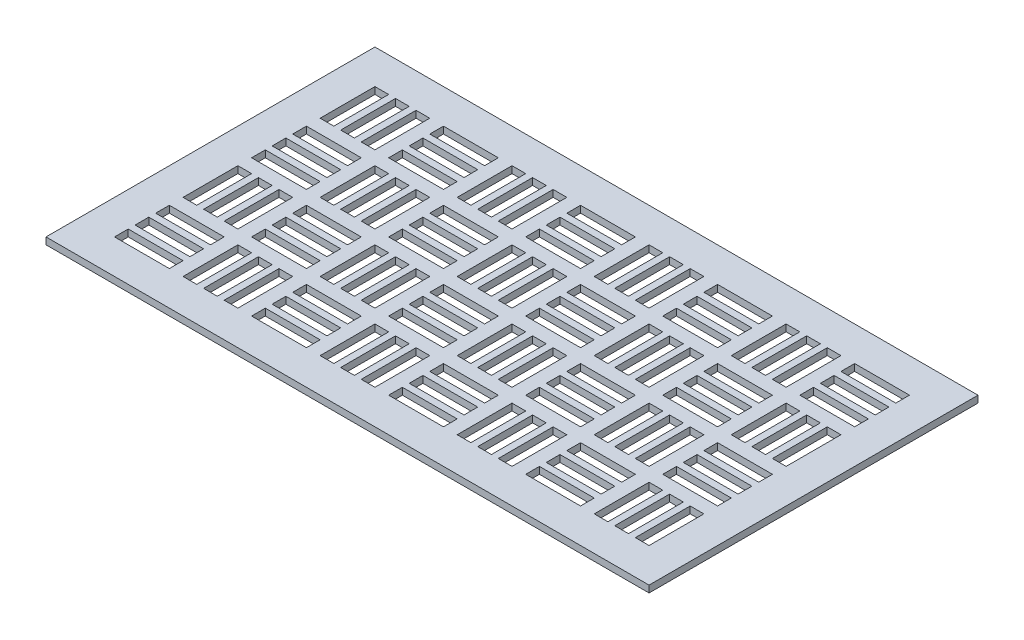
from build123d import *

# Parameters (mm, degrees)
SKETCH2_W           = 558.8
SKETCH2_H           = 304.8
SKETCH2_W_2         = 12.7
SKETCH2_H_2         = 50.8
SKETCH2_W_3         = 50.8
SKETCH2_H_3         = 12.7
BOSS_EXTRUDE1_DEPTH = 6.35


with BuildPart() as part:
    # Sketch2 → Boss-Extrude1 (new body)
    with BuildSketch(Plane(origin=(0, 0, 0), x_dir=(1, 0, 0), z_dir=(0, 1, 0))):
        with Locations((-49.563082079, -65.087132605)):
            Rectangle(SKETCH2_W, SKETCH2_H)
        with Locations((-290.863082079, 30.162867395)):
            Rectangle(SKETCH2_W_2, SKETCH2_H_2, mode=Mode.SUBTRACT)
        with Locations((-252.763082079, 30.162867395)):
            Rectangle(SKETCH2_W_2, SKETCH2_H_2, mode=Mode.SUBTRACT)
        with Locations((-208.313082079, 49.212867395)):
            Rectangle(SKETCH2_W_3, SKETCH2_H_3, mode=Mode.SUBTRACT)
        with Locations((-208.313082079, 11.112867395)):
            Rectangle(SKETCH2_W_3, SKETCH2_H_3, mode=Mode.SUBTRACT)
        with Locations((-227.363082079, -33.337132605)):
            Rectangle(SKETCH2_W_2, SKETCH2_H_2, mode=Mode.SUBTRACT)
        with Locations((-189.263082079, -33.337132605)):
            Rectangle(SKETCH2_W_2, SKETCH2_H_2, mode=Mode.SUBTRACT)
        with Locations((-271.813082079, -14.287132605)):
            Rectangle(SKETCH2_W_3, SKETCH2_H_3, mode=Mode.SUBTRACT)
        with Locations((-271.813082079, -52.387132605)):
            Rectangle(SKETCH2_W_3, SKETCH2_H_3, mode=Mode.SUBTRACT)
        with Locations((-271.813082079, 30.162867395)):
            Rectangle(SKETCH2_W_2, SKETCH2_H_2, mode=Mode.SUBTRACT)
        with Locations((-208.313082079, -33.337132605)):
            Rectangle(SKETCH2_W_2, SKETCH2_H_2, mode=Mode.SUBTRACT)
        with Locations((-208.313082079, 30.162867395)):
            Rectangle(SKETCH2_W_3, SKETCH2_H_3, mode=Mode.SUBTRACT)
        with Locations((-271.813082079, -33.337132605)):
            Rectangle(SKETCH2_W_3, SKETCH2_H_3, mode=Mode.SUBTRACT)
        with Locations((-163.863082079, 30.162867395)):
            Rectangle(SKETCH2_W_2, SKETCH2_H_2, mode=Mode.SUBTRACT)
        with Locations((-144.813082079, 30.162867395)):
            Rectangle(SKETCH2_W_2, SKETCH2_H_2, mode=Mode.SUBTRACT)
        with Locations((-125.763082079, 30.162867395)):
            Rectangle(SKETCH2_W_2, SKETCH2_H_2, mode=Mode.SUBTRACT)
        with Locations((-81.313082079, 11.112867395)):
            Rectangle(SKETCH2_W_3, SKETCH2_H_3, mode=Mode.SUBTRACT)
        with Locations((-81.313082079, 30.162867395)):
            Rectangle(SKETCH2_W_3, SKETCH2_H_3, mode=Mode.SUBTRACT)
        with Locations((-81.313082079, 49.212867395)):
            Rectangle(SKETCH2_W_3, SKETCH2_H_3, mode=Mode.SUBTRACT)
        with Locations((-62.263082079, -33.337132605)):
            Rectangle(SKETCH2_W_2, SKETCH2_H_2, mode=Mode.SUBTRACT)
        with Locations((-81.313082079, -33.337132605)):
            Rectangle(SKETCH2_W_2, SKETCH2_H_2, mode=Mode.SUBTRACT)
        with Locations((-100.363082079, -33.337132605)):
            Rectangle(SKETCH2_W_2, SKETCH2_H_2, mode=Mode.SUBTRACT)
        with Locations((-144.813082079, -52.387132605)):
            Rectangle(SKETCH2_W_3, SKETCH2_H_3, mode=Mode.SUBTRACT)
        with Locations((-144.813082079, -33.337132605)):
            Rectangle(SKETCH2_W_3, SKETCH2_H_3, mode=Mode.SUBTRACT)
        with Locations((-144.813082079, -14.287132605)):
            Rectangle(SKETCH2_W_3, SKETCH2_H_3, mode=Mode.SUBTRACT)
        with Locations((-36.863082079, 30.162867395)):
            Rectangle(SKETCH2_W_2, SKETCH2_H_2, mode=Mode.SUBTRACT)
        with Locations((-17.813082079, 30.162867395)):
            Rectangle(SKETCH2_W_2, SKETCH2_H_2, mode=Mode.SUBTRACT)
        with Locations((1.236917921, 30.162867395)):
            Rectangle(SKETCH2_W_2, SKETCH2_H_2, mode=Mode.SUBTRACT)
        with Locations((45.686917921, 11.112867395)):
            Rectangle(SKETCH2_W_3, SKETCH2_H_3, mode=Mode.SUBTRACT)
        with Locations((45.686917921, 30.162867395)):
            Rectangle(SKETCH2_W_3, SKETCH2_H_3, mode=Mode.SUBTRACT)
        with Locations((45.686917921, 49.212867395)):
            Rectangle(SKETCH2_W_3, SKETCH2_H_3, mode=Mode.SUBTRACT)
        with Locations((64.736917921, -33.337132605)):
            Rectangle(SKETCH2_W_2, SKETCH2_H_2, mode=Mode.SUBTRACT)
        with Locations((45.686917921, -33.337132605)):
            Rectangle(SKETCH2_W_2, SKETCH2_H_2, mode=Mode.SUBTRACT)
        with Locations((26.636917921, -33.337132605)):
            Rectangle(SKETCH2_W_2, SKETCH2_H_2, mode=Mode.SUBTRACT)
        with Locations((-17.813082079, -52.387132605)):
            Rectangle(SKETCH2_W_3, SKETCH2_H_3, mode=Mode.SUBTRACT)
        with Locations((-17.813082079, -33.337132605)):
            Rectangle(SKETCH2_W_3, SKETCH2_H_3, mode=Mode.SUBTRACT)
        with Locations((-17.813082079, -14.287132605)):
            Rectangle(SKETCH2_W_3, SKETCH2_H_3, mode=Mode.SUBTRACT)
        with Locations((90.136917921, 30.162867395)):
            Rectangle(SKETCH2_W_2, SKETCH2_H_2, mode=Mode.SUBTRACT)
        with Locations((109.186917921, 30.162867395)):
            Rectangle(SKETCH2_W_2, SKETCH2_H_2, mode=Mode.SUBTRACT)
        with Locations((128.236917921, 30.162867395)):
            Rectangle(SKETCH2_W_2, SKETCH2_H_2, mode=Mode.SUBTRACT)
        with Locations((172.686917921, 11.112867395)):
            Rectangle(SKETCH2_W_3, SKETCH2_H_3, mode=Mode.SUBTRACT)
        with Locations((172.686917921, 30.162867395)):
            Rectangle(SKETCH2_W_3, SKETCH2_H_3, mode=Mode.SUBTRACT)
        with Locations((172.686917921, 49.212867395)):
            Rectangle(SKETCH2_W_3, SKETCH2_H_3, mode=Mode.SUBTRACT)
        with Locations((191.736917921, -33.337132605)):
            Rectangle(SKETCH2_W_2, SKETCH2_H_2, mode=Mode.SUBTRACT)
        with Locations((172.686917921, -33.337132605)):
            Rectangle(SKETCH2_W_2, SKETCH2_H_2, mode=Mode.SUBTRACT)
        with Locations((153.636917921, -33.337132605)):
            Rectangle(SKETCH2_W_2, SKETCH2_H_2, mode=Mode.SUBTRACT)
        with Locations((109.186917921, -52.387132605)):
            Rectangle(SKETCH2_W_3, SKETCH2_H_3, mode=Mode.SUBTRACT)
        with Locations((109.186917921, -33.337132605)):
            Rectangle(SKETCH2_W_3, SKETCH2_H_3, mode=Mode.SUBTRACT)
        with Locations((109.186917921, -14.287132605)):
            Rectangle(SKETCH2_W_3, SKETCH2_H_3, mode=Mode.SUBTRACT)
        with Locations((-163.863082079, -96.837132605)):
            Rectangle(SKETCH2_W_2, SKETCH2_H_2, mode=Mode.SUBTRACT)
        with Locations((-144.813082079, -96.837132605)):
            Rectangle(SKETCH2_W_2, SKETCH2_H_2, mode=Mode.SUBTRACT)
        with Locations((-125.763082079, -96.837132605)):
            Rectangle(SKETCH2_W_2, SKETCH2_H_2, mode=Mode.SUBTRACT)
        with Locations((-81.313082079, -115.887132605)):
            Rectangle(SKETCH2_W_3, SKETCH2_H_3, mode=Mode.SUBTRACT)
        with Locations((-81.313082079, -96.837132605)):
            Rectangle(SKETCH2_W_3, SKETCH2_H_3, mode=Mode.SUBTRACT)
        with Locations((-81.313082079, -77.787132605)):
            Rectangle(SKETCH2_W_3, SKETCH2_H_3, mode=Mode.SUBTRACT)
        with Locations((-62.263082079, -160.337132605)):
            Rectangle(SKETCH2_W_2, SKETCH2_H_2, mode=Mode.SUBTRACT)
        with Locations((-81.313082079, -160.337132605)):
            Rectangle(SKETCH2_W_2, SKETCH2_H_2, mode=Mode.SUBTRACT)
        with Locations((-100.363082079, -160.337132605)):
            Rectangle(SKETCH2_W_2, SKETCH2_H_2, mode=Mode.SUBTRACT)
        with Locations((-144.813082079, -179.387132605)):
            Rectangle(SKETCH2_W_3, SKETCH2_H_3, mode=Mode.SUBTRACT)
        with Locations((-144.813082079, -160.337132605)):
            Rectangle(SKETCH2_W_3, SKETCH2_H_3, mode=Mode.SUBTRACT)
        with Locations((-144.813082079, -141.287132605)):
            Rectangle(SKETCH2_W_3, SKETCH2_H_3, mode=Mode.SUBTRACT)
        with Locations((-36.863082079, -96.837132605)):
            Rectangle(SKETCH2_W_2, SKETCH2_H_2, mode=Mode.SUBTRACT)
        with Locations((-17.813082079, -96.837132605)):
            Rectangle(SKETCH2_W_2, SKETCH2_H_2, mode=Mode.SUBTRACT)
        with Locations((1.236917921, -96.837132605)):
            Rectangle(SKETCH2_W_2, SKETCH2_H_2, mode=Mode.SUBTRACT)
        with Locations((45.686917921, -115.887132605)):
            Rectangle(SKETCH2_W_3, SKETCH2_H_3, mode=Mode.SUBTRACT)
        with Locations((45.686917921, -96.837132605)):
            Rectangle(SKETCH2_W_3, SKETCH2_H_3, mode=Mode.SUBTRACT)
        with Locations((45.686917921, -77.787132605)):
            Rectangle(SKETCH2_W_3, SKETCH2_H_3, mode=Mode.SUBTRACT)
        with Locations((64.736917921, -160.337132605)):
            Rectangle(SKETCH2_W_2, SKETCH2_H_2, mode=Mode.SUBTRACT)
        with Locations((45.686917921, -160.337132605)):
            Rectangle(SKETCH2_W_2, SKETCH2_H_2, mode=Mode.SUBTRACT)
        with Locations((26.636917921, -160.337132605)):
            Rectangle(SKETCH2_W_2, SKETCH2_H_2, mode=Mode.SUBTRACT)
        with Locations((-17.813082079, -179.387132605)):
            Rectangle(SKETCH2_W_3, SKETCH2_H_3, mode=Mode.SUBTRACT)
        with Locations((-17.813082079, -160.337132605)):
            Rectangle(SKETCH2_W_3, SKETCH2_H_3, mode=Mode.SUBTRACT)
        with Locations((-17.813082079, -141.287132605)):
            Rectangle(SKETCH2_W_3, SKETCH2_H_3, mode=Mode.SUBTRACT)
        with Locations((90.136917921, -96.837132605)):
            Rectangle(SKETCH2_W_2, SKETCH2_H_2, mode=Mode.SUBTRACT)
        with Locations((109.186917921, -96.837132605)):
            Rectangle(SKETCH2_W_2, SKETCH2_H_2, mode=Mode.SUBTRACT)
        with Locations((128.236917921, -96.837132605)):
            Rectangle(SKETCH2_W_2, SKETCH2_H_2, mode=Mode.SUBTRACT)
        with Locations((172.686917921, -115.887132605)):
            Rectangle(SKETCH2_W_3, SKETCH2_H_3, mode=Mode.SUBTRACT)
        with Locations((172.686917921, -96.837132605)):
            Rectangle(SKETCH2_W_3, SKETCH2_H_3, mode=Mode.SUBTRACT)
        with Locations((172.686917921, -77.787132605)):
            Rectangle(SKETCH2_W_3, SKETCH2_H_3, mode=Mode.SUBTRACT)
        with Locations((191.736917921, -160.337132605)):
            Rectangle(SKETCH2_W_2, SKETCH2_H_2, mode=Mode.SUBTRACT)
        with Locations((172.686917921, -160.337132605)):
            Rectangle(SKETCH2_W_2, SKETCH2_H_2, mode=Mode.SUBTRACT)
        with Locations((153.636917921, -160.337132605)):
            Rectangle(SKETCH2_W_2, SKETCH2_H_2, mode=Mode.SUBTRACT)
        with Locations((109.186917921, -179.387132605)):
            Rectangle(SKETCH2_W_3, SKETCH2_H_3, mode=Mode.SUBTRACT)
        with Locations((109.186917921, -160.337132605)):
            Rectangle(SKETCH2_W_3, SKETCH2_H_3, mode=Mode.SUBTRACT)
        with Locations((109.186917921, -141.287132605)):
            Rectangle(SKETCH2_W_3, SKETCH2_H_3, mode=Mode.SUBTRACT)
        with Locations((-290.863082079, -96.837132605)):
            Rectangle(SKETCH2_W_2, SKETCH2_H_2, mode=Mode.SUBTRACT)
        with Locations((-271.813082079, -96.837132605)):
            Rectangle(SKETCH2_W_2, SKETCH2_H_2, mode=Mode.SUBTRACT)
        with Locations((-252.763082079, -96.837132605)):
            Rectangle(SKETCH2_W_2, SKETCH2_H_2, mode=Mode.SUBTRACT)
        with Locations((-208.313082079, -115.887132605)):
            Rectangle(SKETCH2_W_3, SKETCH2_H_3, mode=Mode.SUBTRACT)
        with Locations((-208.313082079, -96.837132605)):
            Rectangle(SKETCH2_W_3, SKETCH2_H_3, mode=Mode.SUBTRACT)
        with Locations((-208.313082079, -77.787132605)):
            Rectangle(SKETCH2_W_3, SKETCH2_H_3, mode=Mode.SUBTRACT)
        with Locations((-189.263082079, -160.337132605)):
            Rectangle(SKETCH2_W_2, SKETCH2_H_2, mode=Mode.SUBTRACT)
        with Locations((-208.313082079, -160.337132605)):
            Rectangle(SKETCH2_W_2, SKETCH2_H_2, mode=Mode.SUBTRACT)
        with Locations((-227.363082079, -160.337132605)):
            Rectangle(SKETCH2_W_2, SKETCH2_H_2, mode=Mode.SUBTRACT)
        with Locations((-271.813082079, -179.387132605)):
            Rectangle(SKETCH2_W_3, SKETCH2_H_3, mode=Mode.SUBTRACT)
        with Locations((-271.813082079, -160.337132605)):
            Rectangle(SKETCH2_W_3, SKETCH2_H_3, mode=Mode.SUBTRACT)
        with Locations((-271.813082079, -141.287132605)):
            Rectangle(SKETCH2_W_3, SKETCH2_H_3, mode=Mode.SUBTRACT)
    extrude(amount=BOSS_EXTRUDE1_DEPTH)


solid = part.part
